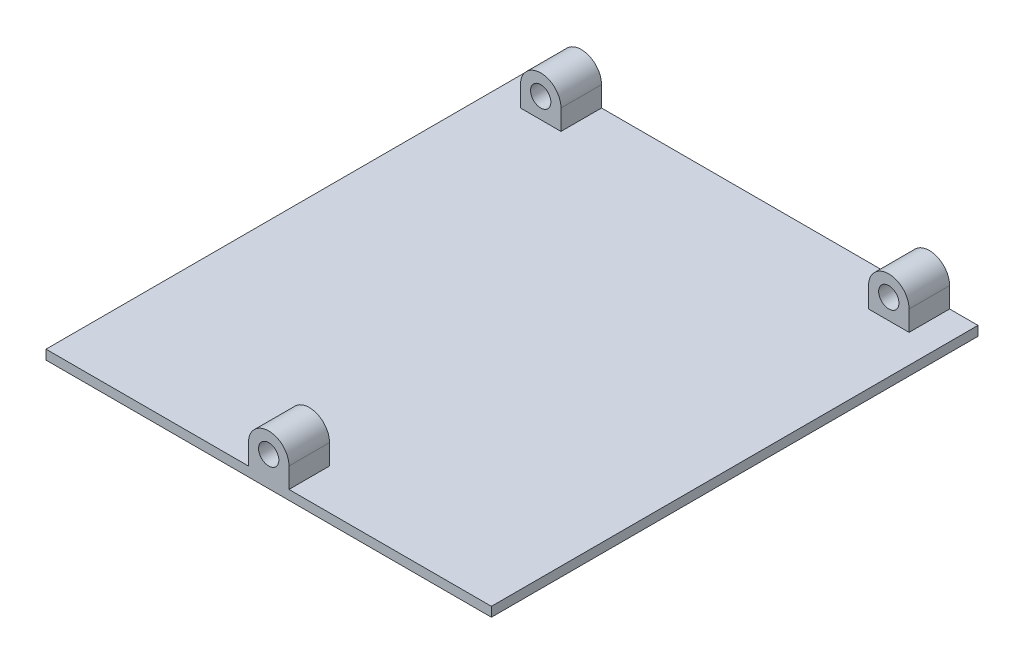
from build123d import *

# Parameters (mm, degrees)
SKETCH1_W           = 139.5
SKETCH1_H           = 152.4
BOSS_EXTRUDE1_DEPTH = 6.35
SKETCH2_W           = 139.5
SKETCH2_H           = 152.4
CUT_EXTRUDE1_DEPTH  = 3.375
SKETCH3_R           = 3.175
BOSS_EXTRUDE2_DEPTH = 12.7
SKETCH4_R           = 3.175000001
SKETCH4_R_2         = 3.175
BOSS_EXTRUDE3_DEPTH = 12.7


with BuildPart() as part:
    # Sketch1 → Boss-Extrude1 (new body)
    with BuildSketch(Plane(origin=(0, 0, 0), x_dir=(1, 0, 0), z_dir=(0, 1, 0))):
        with Locations((69.75, 76.2)):
            Rectangle(SKETCH1_W, SKETCH1_H)
    extrude(amount=BOSS_EXTRUDE1_DEPTH)

    # Sketch2 → Cut-Extrude1 (cut)
    with BuildSketch(Plane(origin=(0, 6.35, 0), x_dir=(1, 0, 0), z_dir=(0, 1, 0))):
        with Locations((69.75, 76.2)):
            Rectangle(SKETCH2_W, SKETCH2_H)
    extrude(amount=-CUT_EXTRUDE1_DEPTH, mode=Mode.SUBTRACT)

    # Sketch3 → Boss-Extrude2 (add)
    with BuildSketch(Plane.XY):
        with BuildLine():
            Line((63.4, 9.325), (63.4, 2.975))
            Line((63.4, 2.975), (76.1, 2.975))
            Line((76.1, 2.975), (76.1, 9.325000633))
            ThreePointArc((76.1, 9.325000633), (69.749999683, 15.675000317), (63.4, 9.325))
        make_face()
        with Locations((69.75, 9.325000317)):
            Circle(SKETCH3_R, mode=Mode.SUBTRACT)
    extrude(amount=-BOSS_EXTRUDE2_DEPTH)

    # Sketch4 → Boss-Extrude3 (add)
    with BuildSketch(Plane(origin=(0, 0, -152.4), x_dir=(-1, 0, 0), z_dir=(0, 0, -1))):
        with BuildLine():
            Line((-130.61, 9.325), (-130.61, 2.975))
            Line((-130.61, 2.975), (-117.91, 2.975))
            Line((-117.91, 2.975), (-117.91, 9.325))
            ThreePointArc((-117.91, 9.325), (-124.26, 15.675), (-130.61, 9.325))
        make_face()
        with Locations((-124.26, 9.325)):
            Circle(SKETCH4_R, mode=Mode.SUBTRACT)
        with BuildLine():
            Line((-21.59, 9.325), (-21.59, 2.975))
            Line((-21.59, 2.975), (-8.89, 2.975))
            Line((-8.89, 2.975), (-8.89, 9.325))
            ThreePointArc((-8.89, 9.325), (-15.24, 15.675), (-21.59, 9.325))
        make_face()
        with Locations((-15.24, 9.325)):
            Circle(SKETCH4_R_2, mode=Mode.SUBTRACT)
    extrude(amount=-BOSS_EXTRUDE3_DEPTH)


solid = part.part
